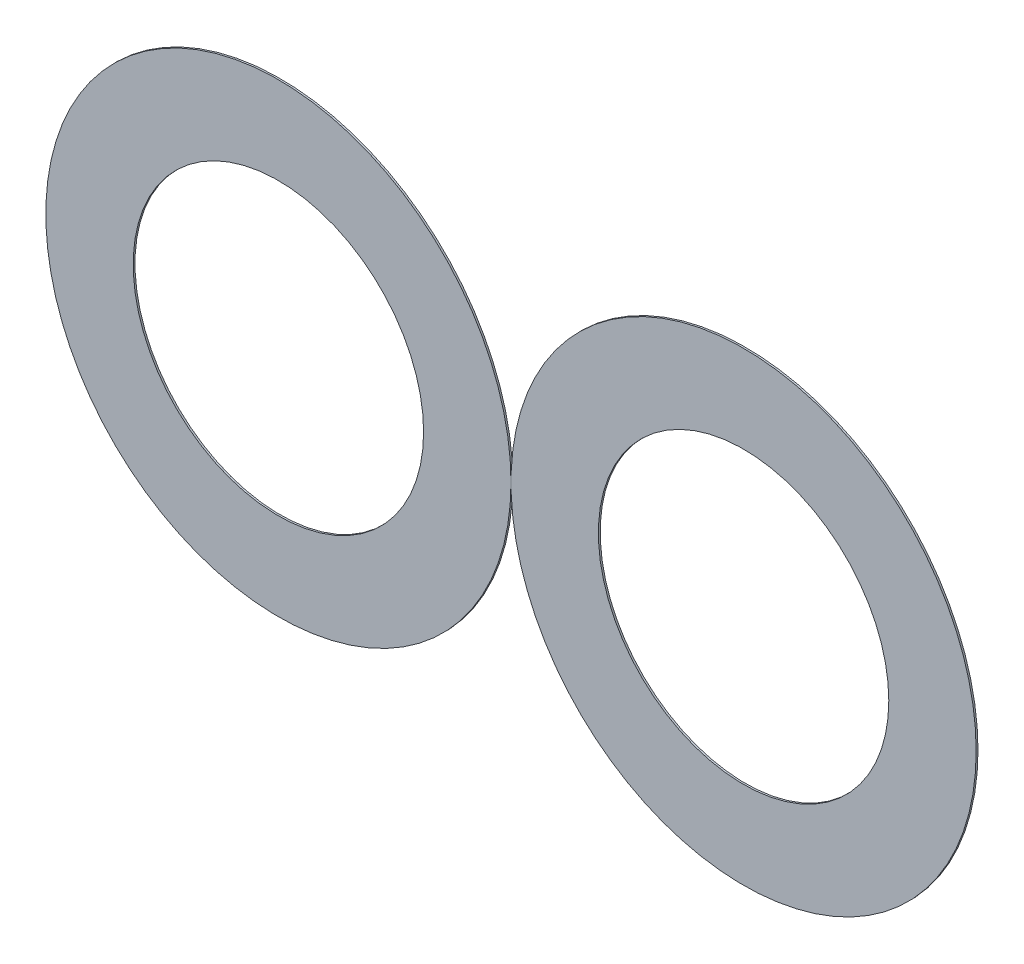
from build123d import *

# Parameters (mm, degrees)
MODEL_R                   = 12.826666667
MODEL_R_2                 = 8.007794723
SALIENTE_EXTRUIR1_DEPTH   = 0.1
SALIENTE_EXTRUIR1_2_DEPTH = 0.1


with BuildPart() as part:
    # Model → Saliente-Extruir1 (new body)
    with BuildSketch(Plane.XY):
        with Locations((14.820646032, 16.6)):
            Circle(MODEL_R)
        with Locations((14.820646032, 16.6)):
            Circle(MODEL_R_2, mode=Mode.SUBTRACT)
    extrude(amount=SALIENTE_EXTRUIR1_DEPTH)


with BuildPart() as body_2:
    # Model → Saliente-Extruir1 2 (new body)
    with BuildSketch(Plane.XY):
        with Locations((40.473979365, 16.6)):
            Circle(MODEL_R)
        with Locations((40.473979365, 16.6)):
            Circle(MODEL_R_2, mode=Mode.SUBTRACT)
    extrude(amount=SALIENTE_EXTRUIR1_2_DEPTH)


solid = Compound([part.part, body_2.part])
